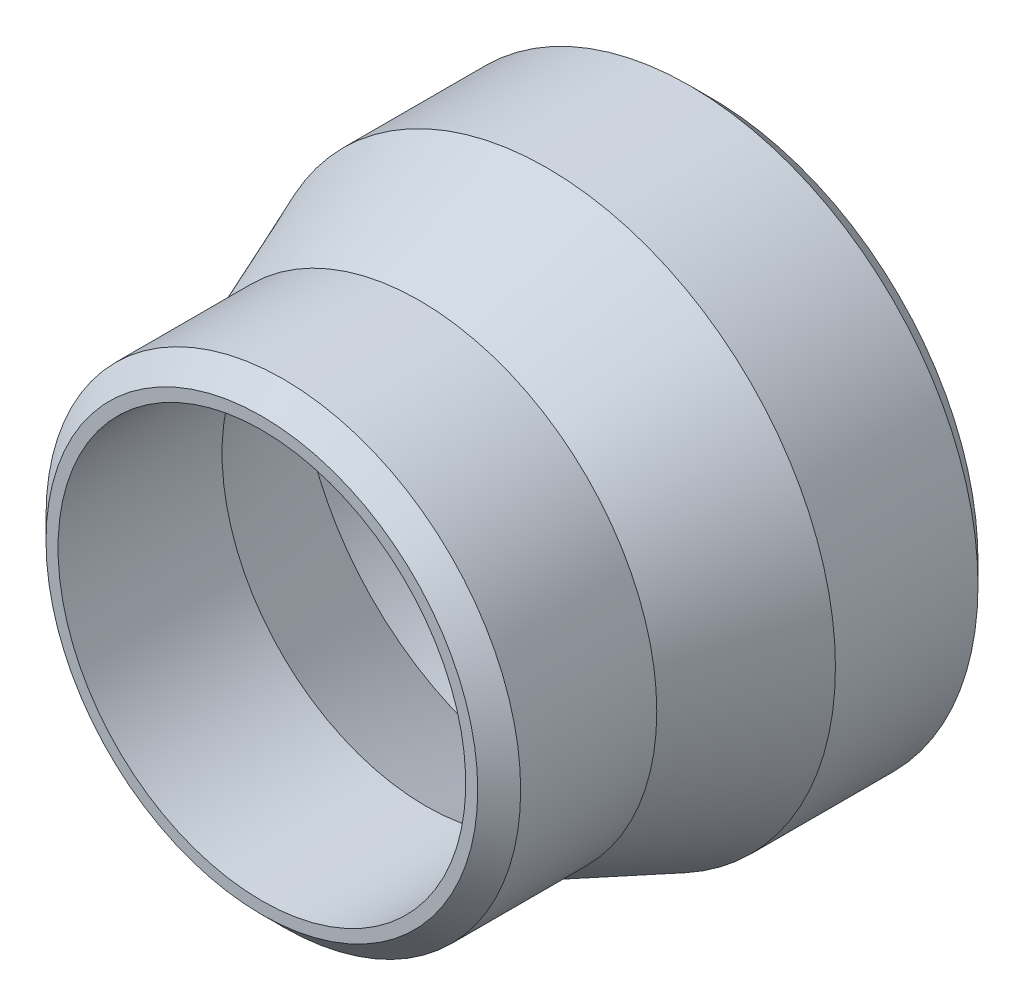
from build123d import *

# Parameters (mm, degrees)
CHAMFER1_SIZE = 2.54


with BuildPart() as part:
    # Sketch1 → Revolve1 (revolve)
    with BuildSketch(Plane(origin=(0, 0, 0), x_dir=(0, 0, -1), z_dir=(1, 0, 0))):
        Polygon((-34.528125, 28.0924), (-53.18125, 28.0924), (-53.18125, 24.13), (-33.766544931, 24.13), (-18.653125, 30.1625), (0, 30.1625), (0, 34.1249), (-19.414705069, 34.1249), align=None)
    revolve(axis=Axis((0, 0, 0), (0, 0, 1)))

    # Chamfer1
    chamfer1_edges = [part.edges().sort_by_distance(p)[0] for p in [
        (0, -34.1249, 0),
        (0, -28.0924, 53.18125),
    ]]
    chamfer(chamfer1_edges, length=CHAMFER1_SIZE)


solid = part.part
